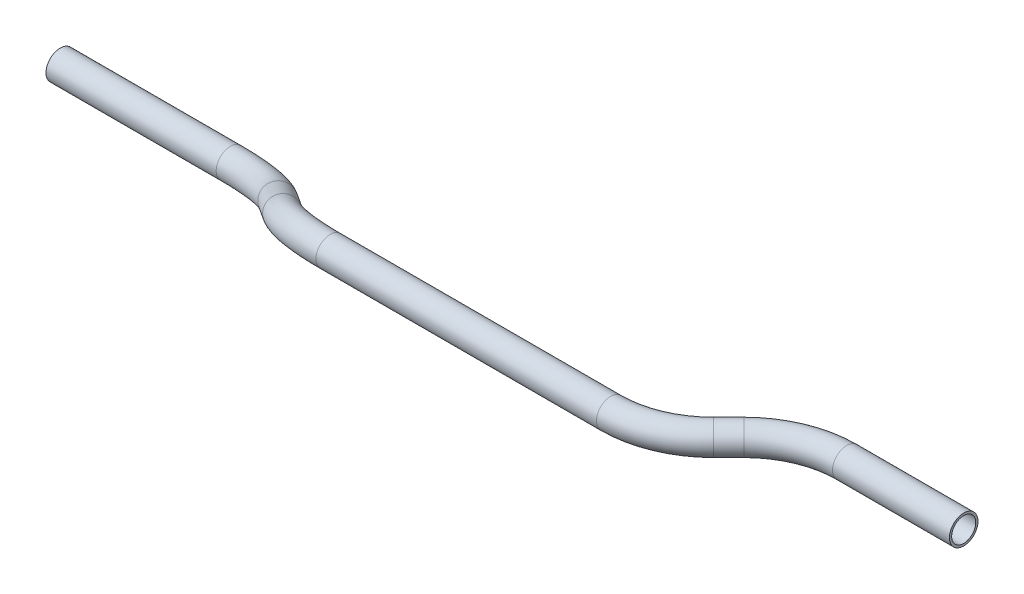
from build123d import *

# Parameters (mm, degrees)
SKETCH1_R   = 7.9375
SKETCH1_R_2 = 6.6929


with BuildPart() as part:
    # Sweep2: sweep along a curve in space
    with BuildLine() as sweep2_path:
        Line((0, 0, 0), (94.566352514, 0, 0))
        ThreePointArc((94.566352514, 0, 0), (116.436710674, 2.371590432, 3.646989984), (134.977505059, 9.125308585, 14.032738769))
        Line((134.977505059, 9.125308585, 14.032738769), (151.4918401, 18.128222538, 27.877261231))
        ThreePointArc((151.4918401, 18.128222538, 27.877261231), (170.032634485, 24.881940691, 38.263010016), (191.902992645, 27.253531123, 41.91))
        Line((191.902992645, 27.253531123, 41.91), (347.758382466, 27.253531123, 41.91))
        ThreePointArc((347.758382466, 27.253531123, 41.91), (369.628740626, 27.253531123, 37.559715283), (388.169535011, 27.253531123, 25.171152545))
        Line((388.169535011, 27.253531123, 25.171152545), (396.6018401, 27.253531123, 16.738847455))
        ThreePointArc((396.6018401, 27.253531123, 16.738847455), (415.142634485, 27.253531123, 4.350284717), (437.012992645, 27.253531123, 0))
        Line((437.012992645, 27.253531123, 0), (501.994161759, 27.253531123, 0))
    # Sketch1 → Sweep2 (sweep)
    with BuildSketch(Plane(origin=(0, 0, 0), x_dir=(0, 0, -1), z_dir=(1, 0, 0))):
        Circle(SKETCH1_R)
        Circle(SKETCH1_R_2, mode=Mode.SUBTRACT)
    sweep(path=sweep2_path.line)


solid = part.part
